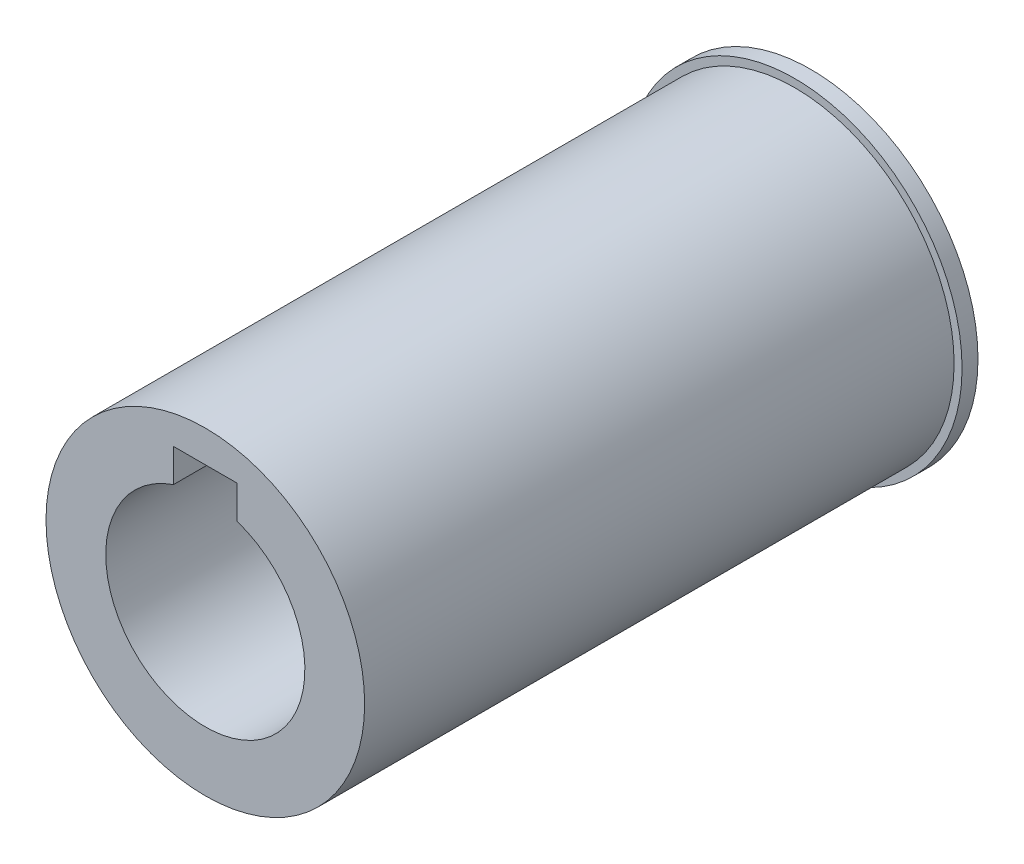
from build123d import *

# Parameters (mm, degrees)
SKETCH1_R                 = 21
BOSS_EXTRUDE1_DEPTH       = 2
SKETCH2_R                 = 20
BOSS_EXTRUDE2_DEPTH       = 74
SKETCH3_R                 = 12.5
CUT_EXTRUDE1_DEPTH        = 77
SKETCH4_W                 = 8
SKETCH4_H                 = 7
CUT_EXTRUDE2_DEPTH        = 76
M6X1_0_TAPPED_HOLE1_D     = 5
M6X1_0_TAPPED_HOLE1_DEPTH = 8.497848452
M6X1_0_TAPPED_HOLE1_TIP   = 1.502151548


with BuildPart() as part:
    # Sketch1 → Boss-Extrude1 (new body)
    with BuildSketch(Plane.XY):
        Circle(SKETCH1_R)
    extrude(amount=BOSS_EXTRUDE1_DEPTH)

    # Sketch2 → Boss-Extrude2 (add)
    with BuildSketch(Plane.XY.offset(2)):
        Circle(SKETCH2_R)
    extrude(amount=BOSS_EXTRUDE2_DEPTH)

    # Sketch3 → Cut-Extrude1 (cut, through all)
    with BuildSketch(Plane(origin=(0, 0, 0), x_dir=(-1, 0, 0), z_dir=(0, 0, -1))):
        Circle(SKETCH3_R)
    extrude(amount=-CUT_EXTRUDE1_DEPTH, mode=Mode.SUBTRACT)

    # Sketch4 → Cut-Extrude2 (cut)
    with BuildSketch(Plane(origin=(0, 0, 0), x_dir=(-1, 0, 0), z_dir=(0, 0, -1))):
        with Locations((0, 12.5)):
            Rectangle(SKETCH4_W, SKETCH4_H)
    extrude(amount=-CUT_EXTRUDE2_DEPTH, mode=Mode.SUBTRACT)

    # M6x1.0 Tapped Hole1
    with Locations(Plane(origin=(0, -20, 0), x_dir=(-1, 0, 0), z_dir=(0, -1, 0))):
        with Locations((0, -56)):
            Hole(M6X1_0_TAPPED_HOLE1_D / 2, depth=M6X1_0_TAPPED_HOLE1_DEPTH)
            with Locations((0, 0, -(M6X1_0_TAPPED_HOLE1_DEPTH + M6X1_0_TAPPED_HOLE1_TIP / 2))):  # 118° drill point
                Cone(0, M6X1_0_TAPPED_HOLE1_D / 2, M6X1_0_TAPPED_HOLE1_TIP, mode=Mode.SUBTRACT)


solid = part.part
